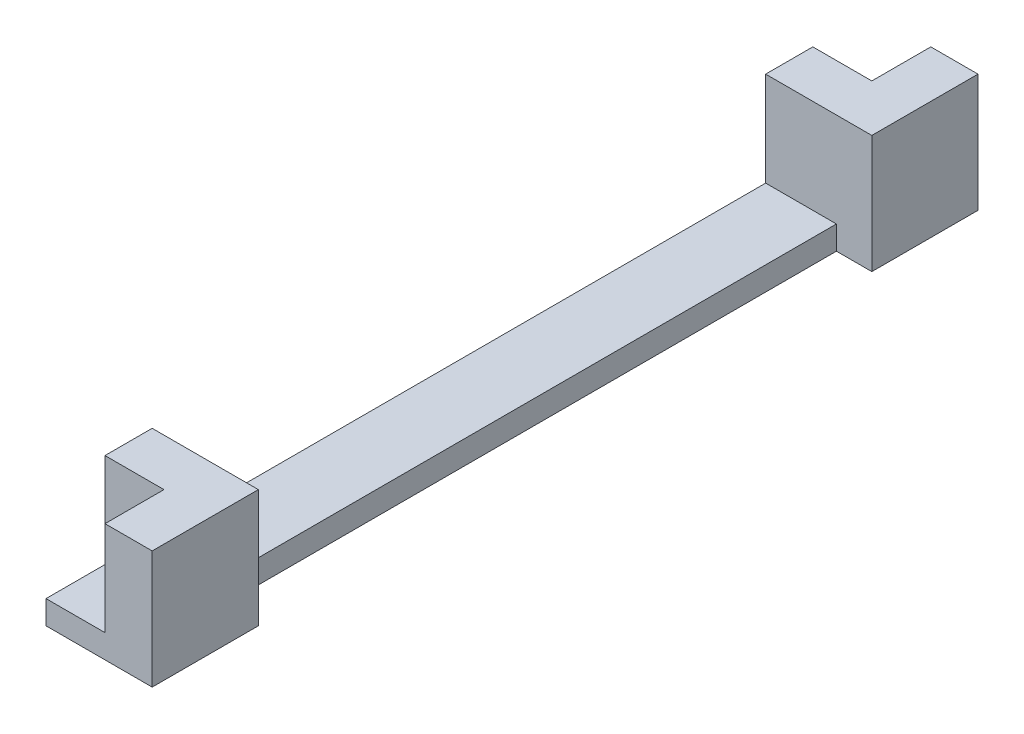
from build123d import *

# Parameters (mm, degrees)
RESSALTO_EXTRUS_O1_DEPTH   = 10
RESSALTO_EXTRUS_O1_2_DEPTH = 10
ESBO_O2_W                  = 9
ESBO_O2_H                  = 70
RESSALTO_EXTRUS_O2_DEPTH   = 2
ESBO_O3_W                  = 3
ESBO_O3_H                  = 52
CORTE_EXTRUS_O1_DEPTH      = 3


with BuildPart() as part:
    # Esboço1 → Ressalto-extrusão1 (new body)
    with BuildSketch(Plane(origin=(0, 0, 0), x_dir=(1, 0, 0), z_dir=(0, 1, 0))):
        Polygon((0.5, -30), (0.5, -35), (4.5, -35), (4.5, -26), (-4.5, -26), (-4.5, -30), align=None)
    extrude(amount=RESSALTO_EXTRUS_O1_DEPTH)



with BuildPart() as body_2:
    # Esboço1 → Ressalto-extrus_o1 2 (new body)
    with BuildSketch(Plane(origin=(0, 0, 0), x_dir=(1, 0, 0), z_dir=(0, 1, 0))):
        Polygon((-4.5, 30), (-4.5, 26), (4.5, 26), (4.5, 35), (0.5, 35), (0.5, 30), align=None)
    extrude(amount=RESSALTO_EXTRUS_O1_2_DEPTH)


with BuildPart() as part_1:
    add(part.part)

    add(body_2.part)  # Ressalto-extrusão2 merges body 2
    # Esboço2 → Ressalto-extrusão2 (add)
    with BuildSketch(Plane(origin=(0, 0, 0), x_dir=(1, 0, 0), z_dir=(0, 1, 0))):
        Rectangle(ESBO_O2_W, ESBO_O2_H)
    extrude(amount=RESSALTO_EXTRUS_O2_DEPTH)

    # Esboço3 → Corte-extrusão1 (cut, through all)
    with BuildSketch(Plane(origin=(0, 2, 0), x_dir=(1, 0, 0), z_dir=(0, 1, 0))):
        with Locations((3, 0)):
            Rectangle(ESBO_O3_W, ESBO_O3_H)
    extrude(amount=-CORTE_EXTRUS_O1_DEPTH, mode=Mode.SUBTRACT)


solid = part_1.part
